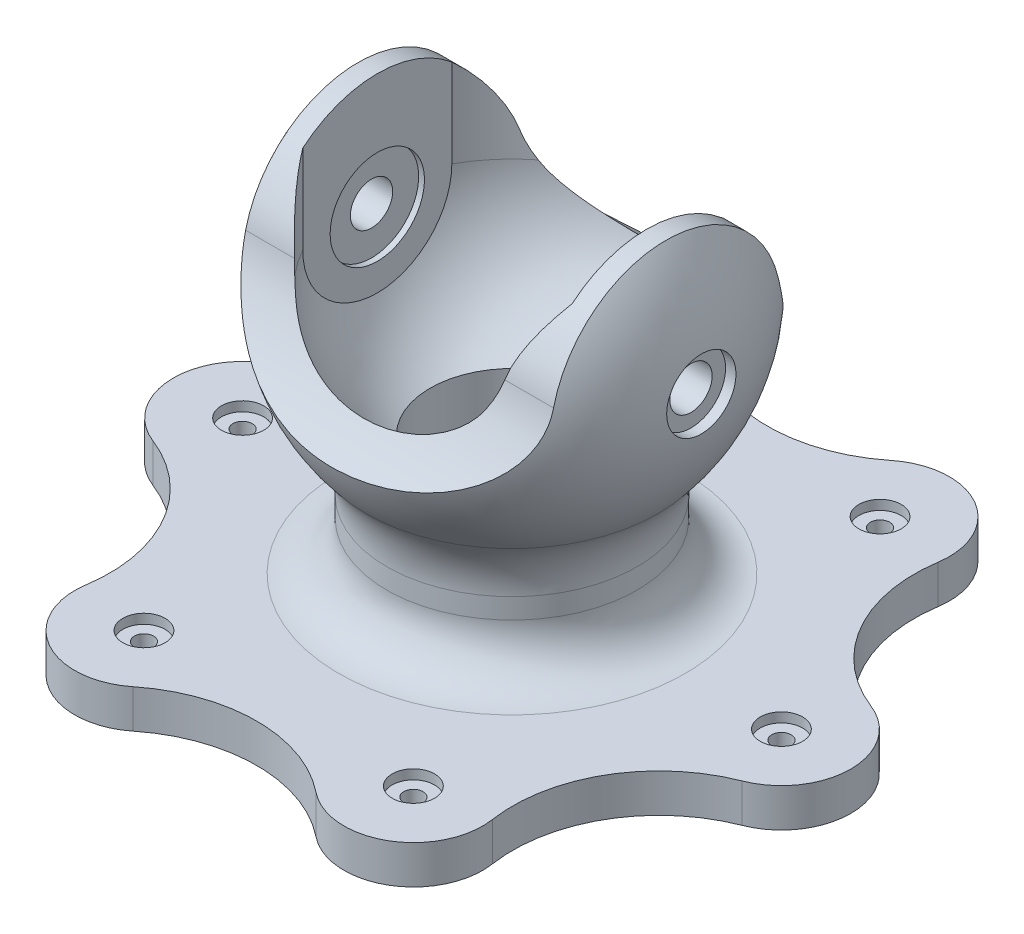
from build123d import *

# Parameters (mm, degrees)
FILLET2_R               = 25
FILLET3_R               = 45
CUT_EXTRUDE1_DEPTH      = 177
CUT_EXTRUDE1_DEPTH_BACK = 177
BOSS_EXTRUDE1_DEPTH     = 10
CUT_EXTRUDE3_DEPTH      = 27
CIRPATTERN1_COUNT       = 6
CIRPATTERN2_COUNT       = 6
CHAMFER1_SIZE           = 1.5


with BuildPart() as part:
    # Sketch1 → Revolve1 (revolve)
    with BuildSketch(Plane.XY):
        with BuildLine():
            Line((0, 0), (60, 0))
            Line((60, 0), (60, -6))
            Line((60, -6), (76, -6))
            Line((76, -6), (76, 0))
            Line((76, 0), (176, 0))
            Line((176, 0), (176, 20))
            Line((176, 20), (65, 20))
            Line((65, 20), (65, 74.006579232))
            ThreePointArc((65, 74.006579232), (93.806561809, 184.645763978), (0, 250))
            Line((0, 250), (0, 0))
        make_face()
    revolve(axis=Axis((0, 0, 0), (0, 1, 0)))

    # Fillet2
    fillet2_edges = [part.edges().sort_by_distance(p)[0] for p in [
        (-65, 20, 0),
    ]]
    fillet(fillet2_edges, radius=FILLET2_R)

    # Fillet3
    fillet3_edges = [part.edges().sort_by_distance(p)[0] for p in [
        (-65, 74.006579232, 0),
    ]]
    fillet(fillet3_edges, radius=FILLET3_R)

    # Sketch2 → Cut-Revolve1 (revolve, cut)
    with BuildSketch(Plane(origin=(0, 0, 0), x_dir=(0, 0, -1), z_dir=(1, 0, 0))):
        with BuildLine():
            Line((0, 0), (32, 0))
            Line((32, 0), (32, 49))
            Line((32, 49), (42.5, 49))
            Line((42.5, 49), (42.5, 82.222791441))
            ThreePointArc((42.5, 82.222791441), (70, 111.270166538), (80, 150))
            Line((80, 150), (80, 250))
            Line((80, 250), (0, 250))
            Line((0, 250), (0, 0))
        make_face()
    revolve(axis=Axis((0, 0, 0), (0, 1, 0)), mode=Mode.SUBTRACT)

    # Sketch3 → Cut-Extrude1 (cut, two sides)
    with BuildSketch(Plane(origin=(0, 0, 0), x_dir=(0, 0, -1), z_dir=(1, 0, 0))) as cut_extrude1_sk:
        with BuildLine():
            ThreePointArc((93.461011894, 114.432609659), (99.022533728, 163.947681312), (80, 210))
            Line((80, 210), (3.99e-07, 210))
            ThreePointArc((3.99e-07, 210), (37.263540361, 197.025828645), (58.4116287, 163.714285714))
            ThreePointArc((58.4116287, 163.714285714), (71.100270782, 135.63402423), (93.461011894, 114.432609659))
        make_face()
        with BuildLine():
            ThreePointArc((-58.4116287, 163.714285714), (-37.263540048, 197.025828893), (3.99e-07, 210))
            Line((3.99e-07, 210), (-80, 210))
            ThreePointArc((-80, 210), (-99.022533728, 163.947681312), (-93.461011894, 114.432609659))
            ThreePointArc((-93.461011894, 114.432609659), (-71.100270782, 135.63402423), (-58.4116287, 163.714285714))
        make_face()
    extrude(amount=CUT_EXTRUDE1_DEPTH, mode=Mode.SUBTRACT)
    extrude(cut_extrude1_sk.sketch, amount=-CUT_EXTRUDE1_DEPTH_BACK, mode=Mode.SUBTRACT)

    # Sketch4 → Boss-Extrude1 (add)
    with BuildSketch(Plane(origin=(70, 0, 0), x_dir=(0, 0, -1), z_dir=(1, 0, 0))):
        with BuildLine():
            Line((38.729833462, 150), (38.729833462, 195.82575695))
            ThreePointArc((38.729833462, 195.82575695), (20.62104002, 206.345121426), (0, 210))
            ThreePointArc((0, 210), (-20.62104002, 206.345121426), (-38.729833462, 195.82575695))
            Line((-38.729833462, 195.82575695), (-38.729833462, 150))
            ThreePointArc((-38.729833462, 150), (0, 111.270166538), (38.729833462, 150))
        make_face()
    boss_extrude1 = extrude(amount=BOSS_EXTRUDE1_DEPTH)

    # Sketch5 → Cut-Revolve2 (revolve, cut)
    with BuildSketch(Plane.XY):
        Polygon((100, 150), (100, 168), (93, 168), (93, 161), (73, 161), (73, 174.5), (70, 174.5), (70, 150), align=None)
    cut_revolve2 = revolve(axis=Axis((0, 150, 0), (1, 0, 0)), mode=Mode.SUBTRACT)

    # Mirror1: Boss-Extrude1, Cut-Revolve2 across plane
    add(boss_extrude1.mirror(Plane(origin=(0, 0, 0), x_dir=(0, 0, 1), z_dir=(1, 0, 0))))
    add(cut_revolve2.mirror(Plane(origin=(0, 0, 0), x_dir=(0, 0, 1), z_dir=(1, 0, 0))), mode=Mode.SUBTRACT)

    # Sketch6 → Cut-Extrude3 (cut, through all)
    with BuildSketch(Plane(origin=(0, 20, 0), x_dir=(1, 0, 0), z_dir=(0, 1, 0))):
        with BuildLine():
            ThreePointArc((105.587471109, 115.809230441), (114.898646097, 66.336764254), (153.087471109, 33.536817082))
            ThreePointArc((153.087471109, 33.536817082), (169.72498074, 20.308262359), (176, 0))
            ThreePointArc((176, 0), (152.420471066, 88), (88, 152.420471066))
            ThreePointArc((88, 152.420471066), (102.449961479, 136.832013798), (105.587471109, 115.809230441))
        make_face()
    cut_extrude3 = extrude(amount=-CUT_EXTRUDE3_DEPTH, mode=Mode.SUBTRACT)

    # CirPattern1: Cut-Extrude3 ×6 about axis
    cirpattern1_axis = Axis((0, 0, 0), (0, 1, 0))
    for i in range(1, CIRPATTERN1_COUNT):
        add(cut_extrude3.rotate(cirpattern1_axis, i * 360 / CIRPATTERN1_COUNT), mode=Mode.SUBTRACT)

    # Sketch7 → Cut-Revolve3 (revolve, cut)
    with BuildSketch(Plane.XY):
        Polygon((140, 0), (157.5, 0), (157.5, 2), (145, 2), (145, 15), (151, 15), (151, 20), (140, 20), align=None)
    cut_revolve3 = revolve(axis=Axis((140, 20, 0), (0, -1, 0)), mode=Mode.SUBTRACT)

    # CirPattern2: Cut-Revolve3 ×6 about axis
    cirpattern2_axis = Axis((0, 0, 0), (0, 1, 0))
    for i in range(1, CIRPATTERN2_COUNT):
        add(cut_revolve3.rotate(cirpattern2_axis, i * 360 / CIRPATTERN2_COUNT), mode=Mode.SUBTRACT)

    # Chamfer1
    chamfer1_edges = [part.edges().sort_by_distance(p)[0] for p in [
        (-76, -6, 0),
    ]]
    chamfer(chamfer1_edges, length=CHAMFER1_SIZE)


solid = part.part
